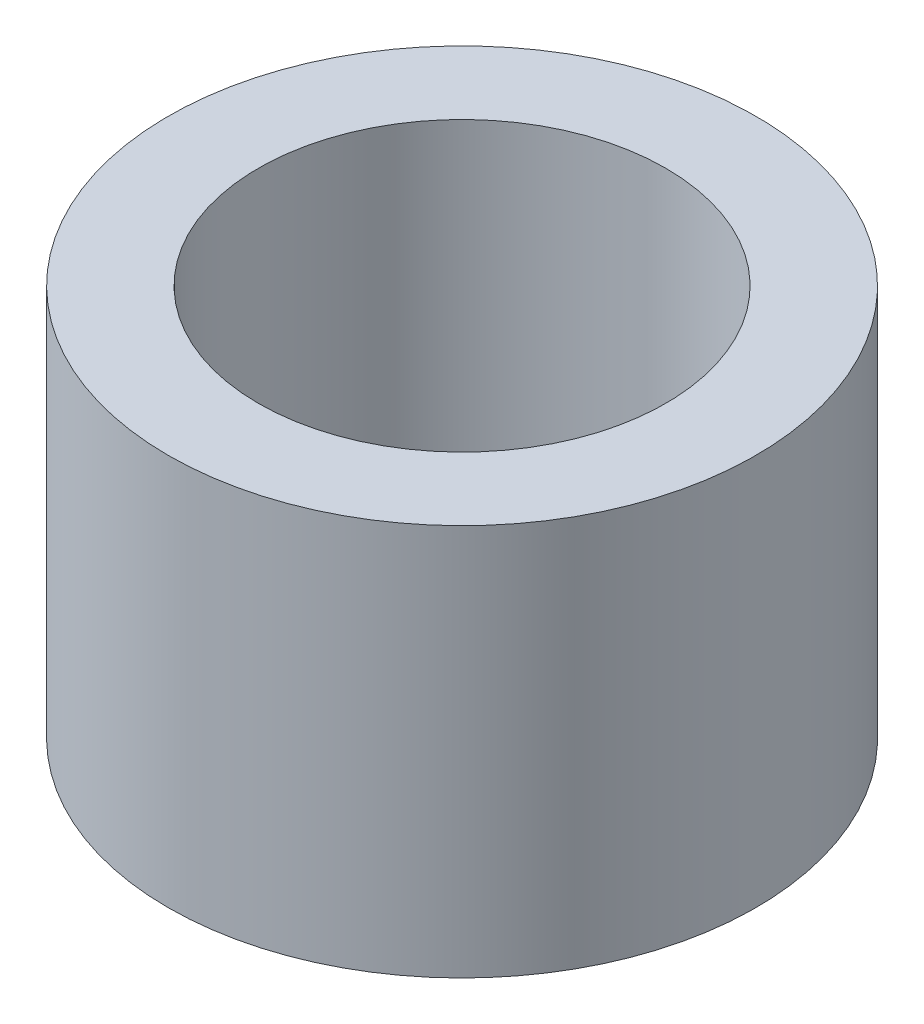
from build123d import *

# Parameters (mm, degrees)
SKETCH2_R           = 4.7625
SKETCH2_R_2         = 3.302
BOSS_EXTRUDE1_DEPTH = 6.35


with BuildPart() as part:
    # Sketch2 → Boss-Extrude1 (new body)
    with BuildSketch(Plane(origin=(0, 0, 0), x_dir=(1, 0, 0), z_dir=(0, 1, 0))):
        Circle(SKETCH2_R)
        Circle(SKETCH2_R_2, mode=Mode.SUBTRACT)
    extrude(amount=BOSS_EXTRUDE1_DEPTH)


solid = part.part
